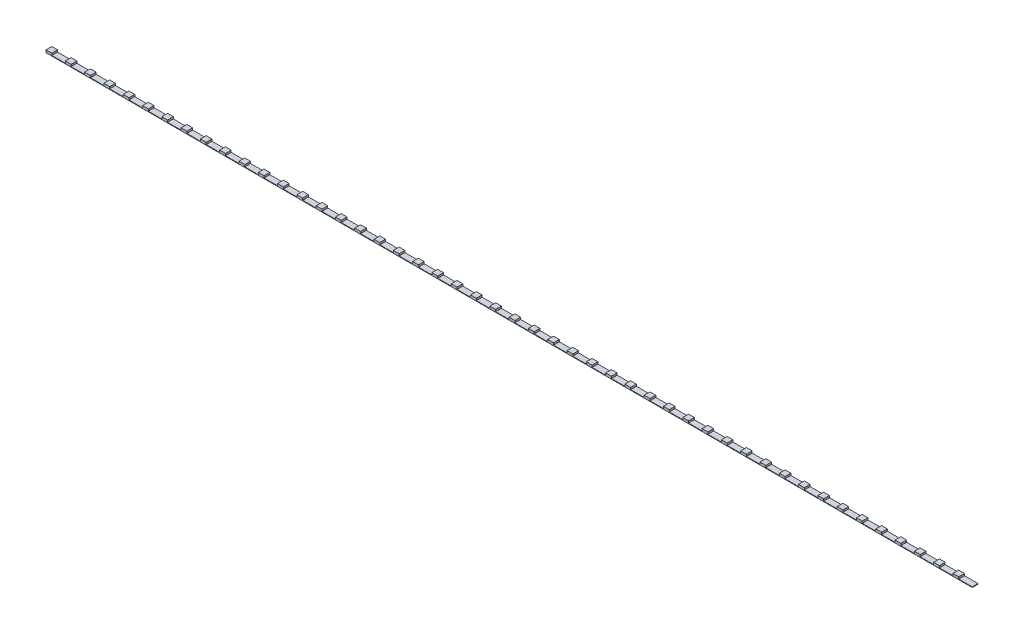
from build123d import *

# Parameters (mm, degrees)
SKETCH_1_W             = 800
SKETCH_1_H             = 5
EXTRUDE_1_DEPTH        = 0.5
SKETCH_2_W             = 5
SKETCH_2_H             = 5
EXTRUDE_2_DEPTH        = 1.7
PATTERN_LINEAR_1_COUNT = 48
PATTERN_LINEAR_1_PITCH = 16.666666667


with BuildPart() as part:
    # 草图1 → 凸台-拉伸1 (new body)
    with BuildSketch(Plane(origin=(0, 0, 0), x_dir=(1, 0, 0), z_dir=(0, 1, 0))):
        Rectangle(SKETCH_1_W, SKETCH_1_H)
    extrude(amount=EXTRUDE_1_DEPTH)

    # 草图2 → 凸台-拉伸2 (add)
    with BuildSketch(Plane(origin=(0, 0.5, 0), x_dir=(1, 0, 0), z_dir=(0, 1, 0))):
        with Locations((-397.5, 0)):
            Rectangle(SKETCH_2_W, SKETCH_2_H)
    extrude_2 = extrude(amount=EXTRUDE_2_DEPTH)

    # 阵列(线性)1: 凸台-拉伸2 ×48
    with Locations(*[(i * PATTERN_LINEAR_1_PITCH, 0, 0) for i in range(1, PATTERN_LINEAR_1_COUNT)]):
        add(extrude_2)


solid = part.part
